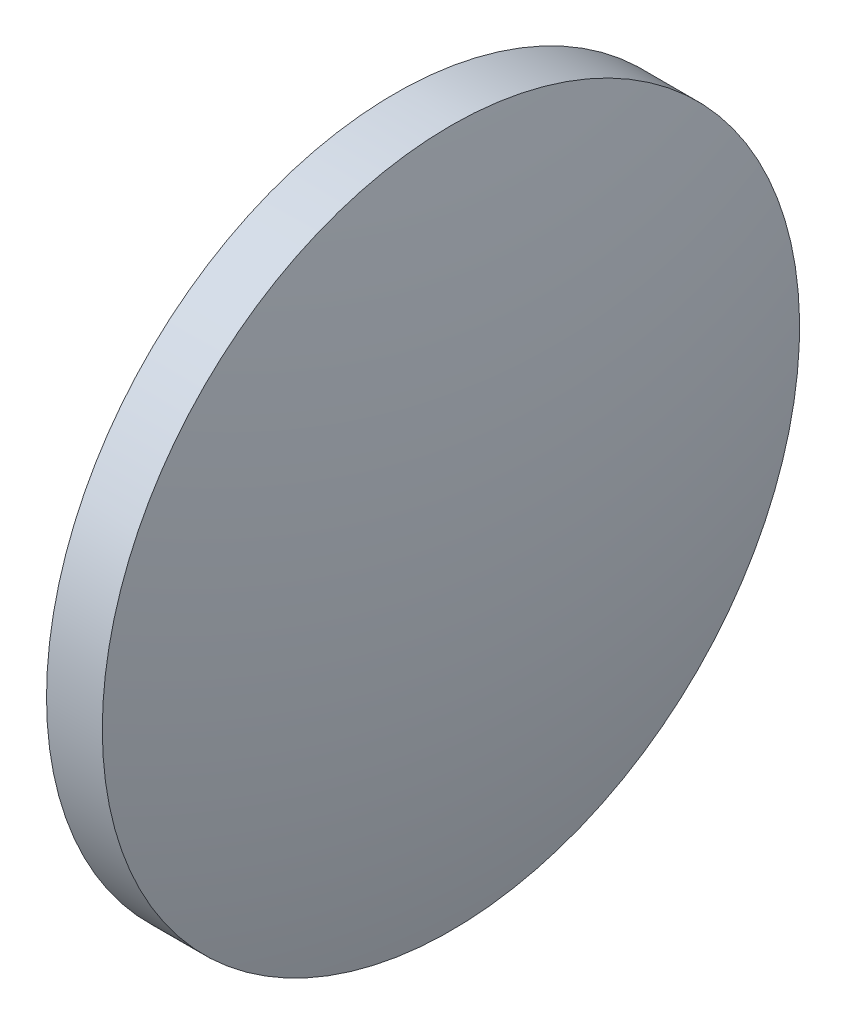
from build123d import *


with BuildPart() as part:
    # 草图1 → 旋转1 (revolve)
    with BuildSketch(Plane.XY):
        with BuildLine():
            Line((56.698403068, 32.51047269), (56.698403068, 45.01047269))
            Line((56.698403068, 45.01047269), (58.698403068, 45.01047269))
            ThreePointArc((58.698403068, 45.01047269), (59.851953145, 38.80772606), (60.238403068, 32.51047269))
            Line((60.238403068, 32.51047269), (56.698403068, 32.51047269))
        make_face()
    revolve(axis=Axis((54.332787165, 32.51047269, 0), (1, 0, 0)))


solid = part.part
